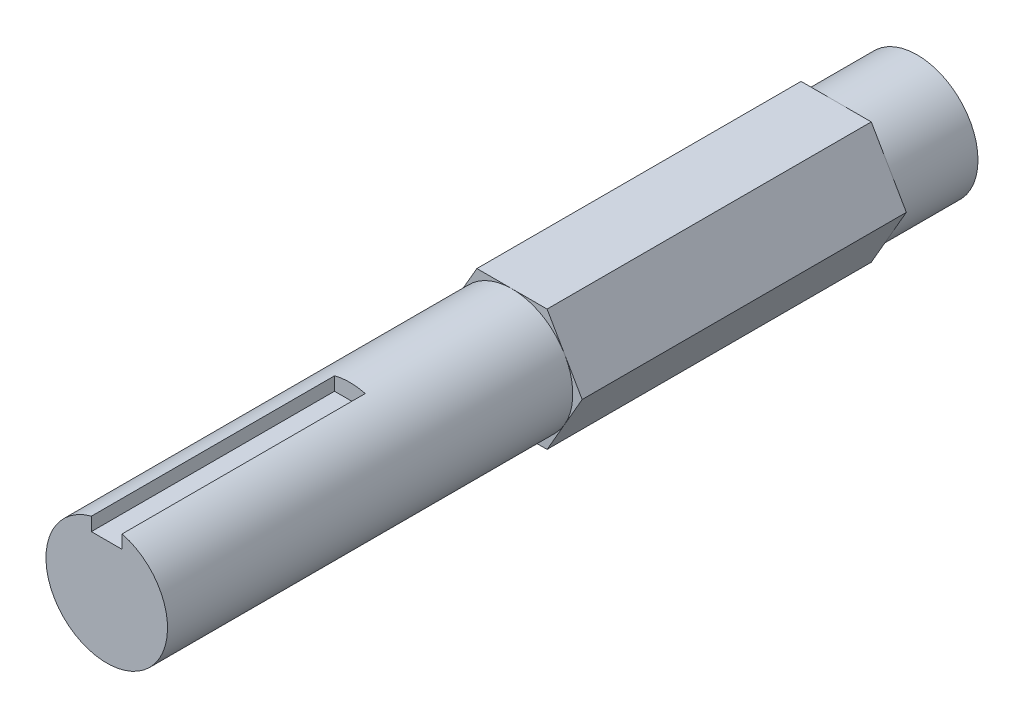
from build123d import *

# Parameters (mm, degrees)
BOSS_EXTRUDE1_DEPTH = 63.5
SKETCH2_OUTSIDE_W   = 26.028
SKETCH2_OUTSIDE_H   = 24.556
SKETCH2_OUTSIDE_R   = 4.7625
CUT_EXTRUDE1_DEPTH  = 31.75
SKETCH3_OUTSIDE_W   = 26.028
SKETCH3_OUTSIDE_H   = 24.556
SKETCH3_OUTSIDE_R   = 4.7625
CUT_EXTRUDE2_DEPTH  = 6.35
SKETCH4_W           = 2.40792
SKETCH4_H           = 2.40792
CUT_EXTRUDE3_DEPTH  = 19.05


with BuildPart() as part:
    # Sketch1 → Boss-Extrude1 (new body)
    with BuildSketch(Plane.XY):
        Polygon((-2.749630657, -4.7625), (2.749630657, -4.7625), (5.499261314, 0), (2.749630657, 4.7625), (-2.749630657, 4.7625), (-5.499261314, 0), align=None)
    extrude(amount=BOSS_EXTRUDE1_DEPTH)

    # Sketch2 outside → Cut-Extrude1 (cut)
    with BuildSketch(Plane.XY.offset(63.5)):
        Rectangle(SKETCH2_OUTSIDE_W, SKETCH2_OUTSIDE_H)
        Circle(SKETCH2_OUTSIDE_R, mode=Mode.SUBTRACT)
    extrude(amount=-CUT_EXTRUDE1_DEPTH, mode=Mode.SUBTRACT)

    # Sketch3 outside → Cut-Extrude2 (cut)
    with BuildSketch(Plane(origin=(0, 0, 0), x_dir=(-1, 0, 0), z_dir=(0, 0, -1))):
        Rectangle(SKETCH3_OUTSIDE_W, SKETCH3_OUTSIDE_H)
        with Locations(Location((0, 0, 0), (0, 0, 180))):  # turned: the seam where the file's is
            Circle(SKETCH3_OUTSIDE_R, mode=Mode.SUBTRACT)
    extrude(amount=-CUT_EXTRUDE2_DEPTH, mode=Mode.SUBTRACT)

    # Sketch4 → Cut-Extrude3 (cut)
    with BuildSketch(Plane.XY.offset(63.5)):
        with Locations((0, 4.7625)):
            Rectangle(SKETCH4_W, SKETCH4_H)
    extrude(amount=-CUT_EXTRUDE3_DEPTH, mode=Mode.SUBTRACT)


solid = part.part
